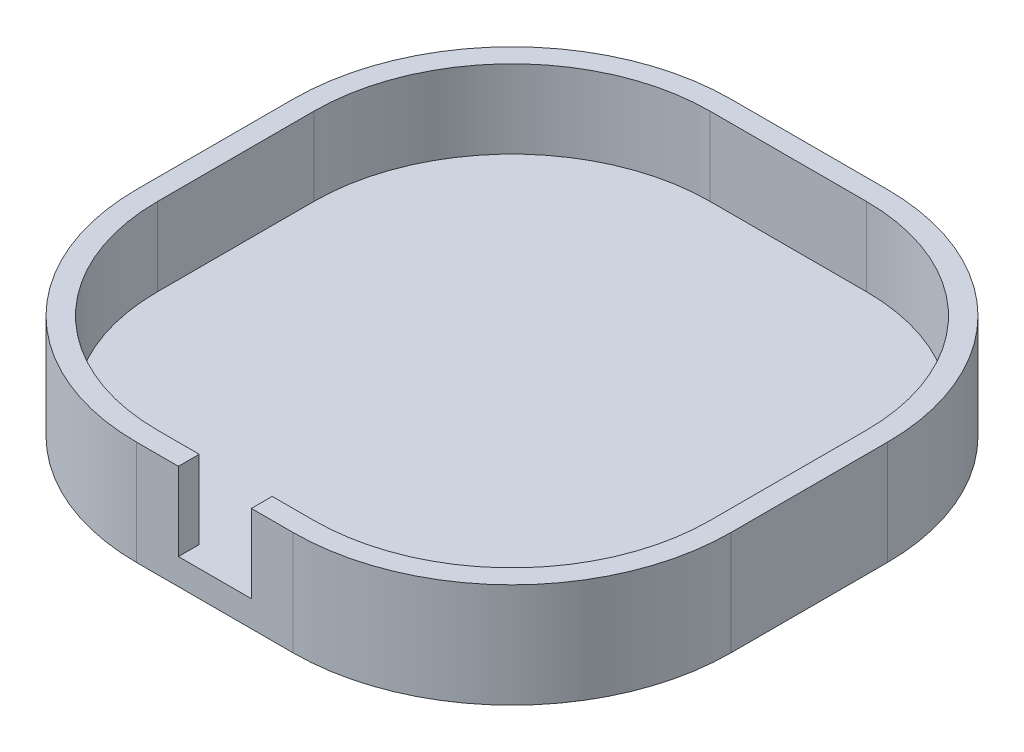
from build123d import *

# Parameters (mm, degrees)
BOSS_EXTRUDE1_DEPTH = 5
BOSS_EXTRUDE2_DEPTH = 15
SKETCH3_W           = 14
SKETCH3_H           = 4
CUT_EXTRUDE1_DEPTH  = 15


with BuildPart() as part:
    # Sketch1 → Boss-Extrude1 (new body)
    with BuildSketch(Plane(origin=(0, 0, 0), x_dir=(1, 0, 0), z_dir=(0, 1, 0))):
        with BuildLine():
            Line((-15, -57), (15, -57))
            ThreePointArc((15, -57), (44.69848481, -44.69848481), (57, -15))
            Line((57, -15), (57, 15))
            ThreePointArc((57, 15), (44.69848481, 44.69848481), (15, 57))
            Line((15, 57), (-15, 57))
            ThreePointArc((-15, 57), (-44.69848481, 44.69848481), (-57, 15))
            Line((-57, 15), (-57, -15))
            ThreePointArc((-57, -15), (-44.69848481, -44.69848481), (-15, -57))
        make_face()
    extrude(amount=BOSS_EXTRUDE1_DEPTH)

    # Sketch2 → Boss-Extrude2 (add)
    with BuildSketch(Plane(origin=(0, 5, 0), x_dir=(1, 0, 0), z_dir=(0, 1, 0))):
        with BuildLine():
            Line((57, -15), (57, 15))
            ThreePointArc((57, 15), (44.69848481, 44.69848481), (15, 57))
            Line((15, 57), (-15, 57))
            ThreePointArc((-15, 57), (-44.69848481, 44.69848481), (-57, 15))
            Line((-57, 15), (-57, -15))
            ThreePointArc((-57, -15), (-44.69848481, -44.69848481), (-15, -57))
            Line((-15, -57), (15, -57))
            ThreePointArc((15, -57), (44.69848481, -44.69848481), (57, -15))
        make_face()
        with BuildLine():
            Line((-53, 15), (-53, -15))
            ThreePointArc((-53, -15), (-41.870057685, -41.870057685), (-15, -53))
            Line((-15, -53), (15, -53))
            ThreePointArc((15, -53), (41.870057685, -41.870057685), (53, -15))
            Line((53, -15), (53, 15))
            ThreePointArc((53, 15), (41.870057685, 41.870057685), (15, 53))
            Line((15, 53), (-15, 53))
            ThreePointArc((-15, 53), (-41.870057685, 41.870057685), (-53, 15))
        make_face(mode=Mode.SUBTRACT)
    extrude(amount=BOSS_EXTRUDE2_DEPTH)

    # Sketch3 → Cut-Extrude1 (cut)
    with BuildSketch(Plane(origin=(0, 20, 0), x_dir=(1, 0, 0), z_dir=(0, 1, 0))):
        with Locations((0, -55)):
            Rectangle(SKETCH3_W, SKETCH3_H)
    extrude(amount=-CUT_EXTRUDE1_DEPTH, mode=Mode.SUBTRACT)


solid = part.part
